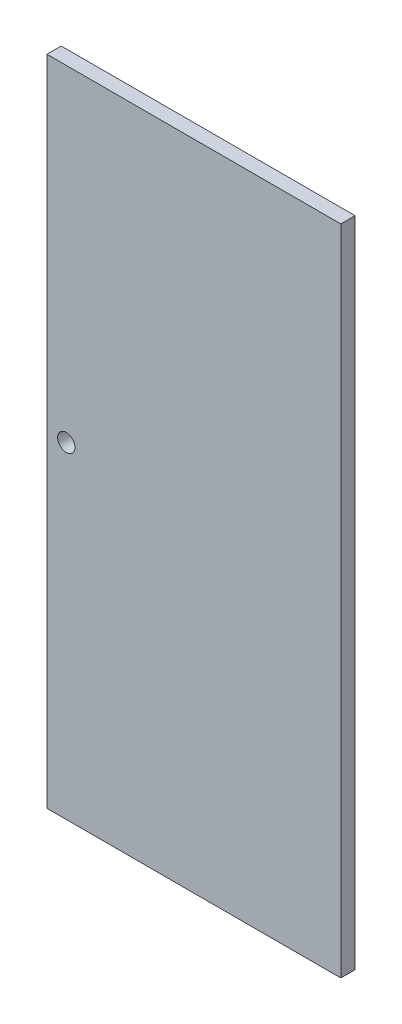
from build123d import *

# Parameters (mm, degrees)
SKETCH1_W           = 914.4
SKETCH1_H           = 2032
BOSS_EXTRUDE1_DEPTH = 44.45
SKETCH2_R           = 26.9875
CUT_EXTRUDE1_DEPTH  = 44.45


with BuildPart() as part:
    # Sketch1 → Boss-Extrude1 (new body)
    with BuildSketch(Plane.XY):
        with Locations((1116.171038615, 1018.392876165)):
            Rectangle(SKETCH1_W, SKETCH1_H)
    extrude(amount=BOSS_EXTRUDE1_DEPTH)

    # Sketch2 → Cut-Extrude1 (cut)
    with BuildSketch(Plane.XY.offset(44.45)):
        with Locations((719.296038615, 1018.392876165)):
            Circle(SKETCH2_R)
    extrude(amount=-CUT_EXTRUDE1_DEPTH, mode=Mode.SUBTRACT)


solid = part.part
